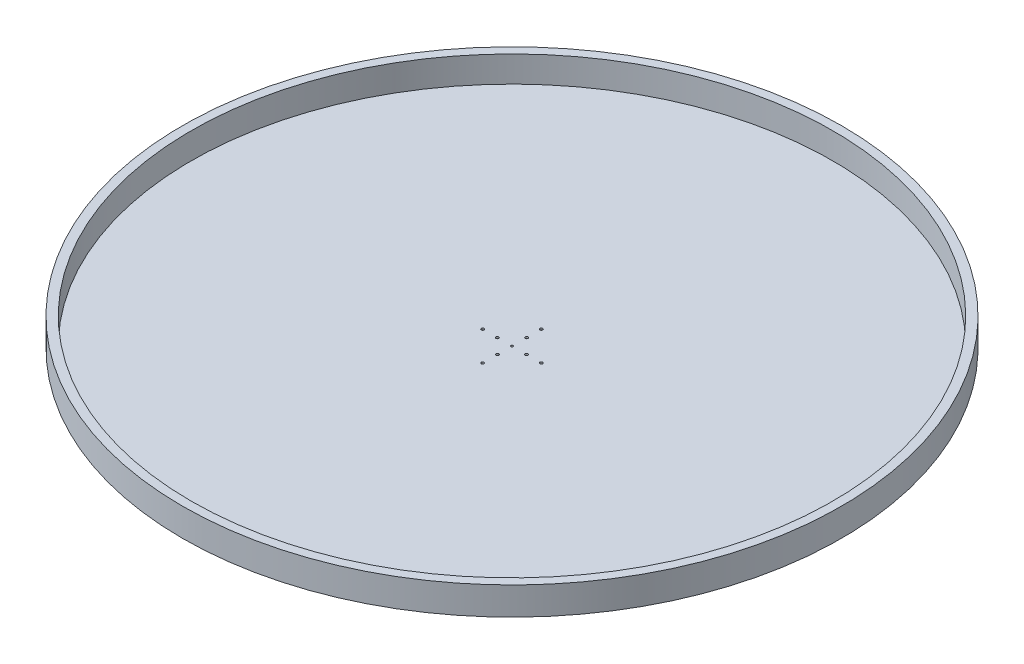
from build123d import *

# Parameters (mm, degrees)
SKETCH1_R           = 472.5
BOSS_EXTRUDE1_DEPTH = 40
SKETCH3_R           = 460
CUT_EXTRUDE1_DEPTH  = 37.46
SKETCH5_R           = 1.5
CUT_EXTRUDE3_DEPTH  = 3.54
SKETCH8_R           = 2.02
CUT_EXTRUDE4_DEPTH  = 3.54


with BuildPart() as part:
    # Sketch1 → Boss-Extrude1 (new body)
    with BuildSketch(Plane(origin=(0, 0, 0), x_dir=(1, 0, 0), z_dir=(0, 1, 0))):
        Circle(SKETCH1_R)
    extrude(amount=BOSS_EXTRUDE1_DEPTH)

    # Sketch3 → Cut-Extrude1 (cut)
    with BuildSketch(Plane(origin=(0, 40, 0), x_dir=(1, 0, 0), z_dir=(0, 1, 0))):
        Circle(SKETCH3_R)
    extrude(amount=-CUT_EXTRUDE1_DEPTH, mode=Mode.SUBTRACT)

    # Sketch5 → Cut-Extrude3 (cut, through all)
    with BuildSketch(Plane(origin=(0, 2.54, 0), x_dir=(1, 0, 0), z_dir=(0, 1, 0))):
        Circle(SKETCH5_R)
    extrude(amount=-CUT_EXTRUDE3_DEPTH, mode=Mode.SUBTRACT)

    # Sketch8 → Cut-Extrude4 (cut, through all)
    with BuildSketch(Plane(origin=(0, 2.54, 0), x_dir=(1, 0, 0), z_dir=(0, 1, 0))):
        with Locations((0, 42)):
            Circle(SKETCH8_R)
        with Locations((42, 0)):
            Circle(SKETCH8_R)
        with Locations((0, -42)):
            Circle(SKETCH8_R)
        with Locations((-42, 0)):
            Circle(SKETCH8_R)
        with Locations((0, 21)):
            Circle(SKETCH8_R)
        with Locations((21, 0)):
            Circle(SKETCH8_R)
        with Locations((0, -21)):
            Circle(SKETCH8_R)
        with Locations((-21, 0)):
            Circle(SKETCH8_R)
    extrude(amount=-CUT_EXTRUDE4_DEPTH, mode=Mode.SUBTRACT)


solid = part.part
